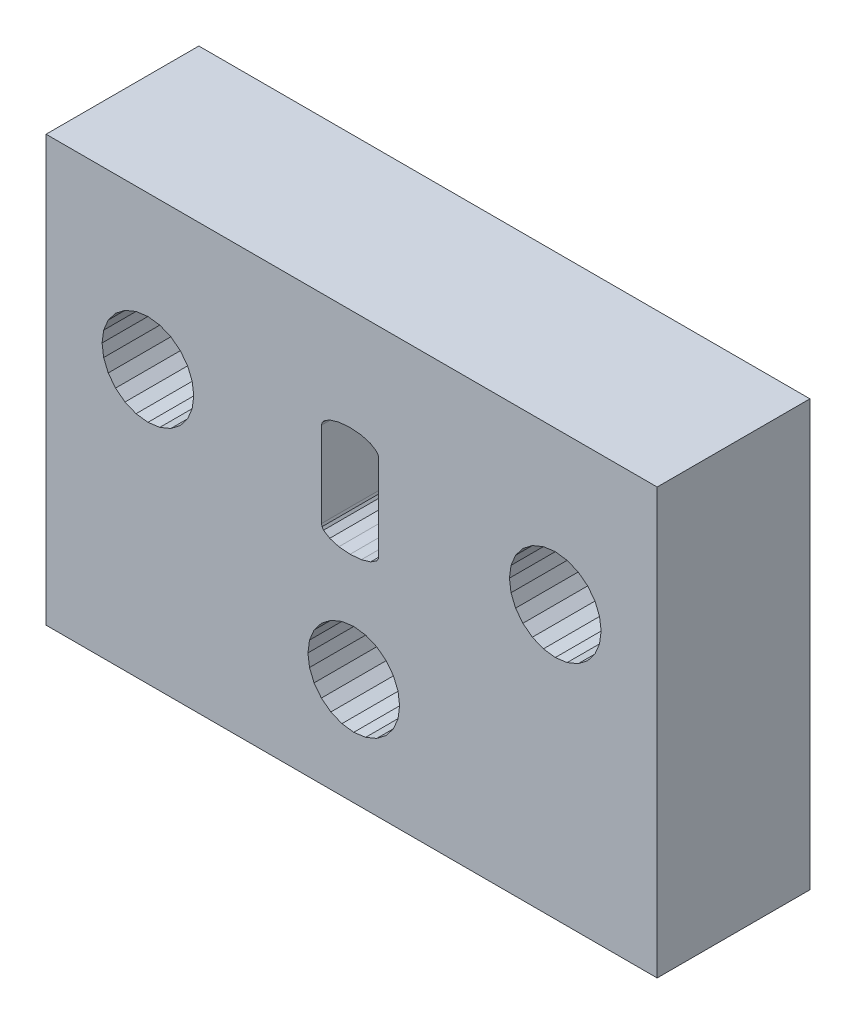
from build123d import *

# Parameters (mm, degrees)
SKETCH1_W           = 23.99999232
SKETCH1_H           = 16.699994656
BOSS_EXTRUDE1_DEPTH = 6


with BuildPart() as part:
    # Sketch1 → Boss-Extrude1 (new body)
    with BuildSketch(Plane.XY):
        with Locations((252.776898883, 87.516141094)):
            Rectangle(SKETCH1_W, SKETCH1_H)
        Polygon((254.420508276, 82.46614271), (254.600328979, 82.90026829), (254.661662472, 83.366142422), (254.600328979, 83.832016554), (254.420508276, 84.266142134), (254.134454846, 84.638934221), (253.76166276, 84.92498765), (253.32753718, 85.104808353), (252.861663048, 85.166141846), (252.395788915, 85.104808353), (251.961663336, 84.92498765), (251.588871249, 84.638934221), (251.30281782, 84.266142134), (251.122997117, 83.832016554), (251.061663624, 83.366142422), (251.122997117, 82.90026829), (251.30281782, 82.46614271), (251.588871249, 82.093350624), (251.961663336, 81.807297194), (252.395788915, 81.627476491), (252.861663048, 81.566142998), (253.32753718, 81.627476491), (253.76166276, 81.807297194), (254.134454846, 82.093350624), align=None, mode=Mode.SUBTRACT)
        Polygon((260.30990578, 88.127474411), (260.775779912, 88.066140918), (261.241654045, 88.127474411), (261.675779624, 88.307295114), (262.048571711, 88.593348544), (262.33462514, 88.96614063), (262.514445843, 89.40026621), (262.575779336, 89.866140342), (262.514445843, 90.332014474), (262.33462514, 90.766140054), (262.048571711, 91.138932141), (261.675779624, 91.42498557), (261.241654045, 91.604806273), (260.775779912, 91.666139766), (260.30990578, 91.604806273), (259.8757802, 91.42498557), (259.502988114, 91.138932141), (259.216934685, 90.766140054), (259.037113982, 90.332014474), (258.975780488, 89.866140342), (259.037113982, 89.40026621), (259.216934685, 88.96614063), (259.502988114, 88.593348544), (259.8757802, 88.307295114), align=None, mode=Mode.SUBTRACT)
        Polygon((246.335746671, 90.766140054), (246.049693242, 91.138932141), (245.676901155, 91.42498557), (245.242775575, 91.604806273), (244.776901443, 91.666139766), (244.311027311, 91.604806273), (243.876901731, 91.42498557), (243.504109644, 91.138932141), (243.218056215, 90.766140054), (243.038235512, 90.332014474), (242.976902019, 89.866140342), (243.038235512, 89.40026621), (243.218056215, 88.96614063), (243.504109644, 88.593348544), (243.876901731, 88.307295114), (244.311027311, 88.127474411), (244.776901443, 88.066140918), (245.242775575, 88.127474411), (245.676901155, 88.307295114), (246.049693242, 88.593348544), (246.335746671, 88.96614063), (246.515567374, 89.40026621), (246.576900867, 89.866140342), (246.515567374, 90.332014474), align=None, mode=Mode.SUBTRACT)
        Polygon((251.594211482, 88.030941424), (251.614308424, 87.934752995), (251.674599249, 87.845978104), (251.91576255, 87.690668939), (252.277126402, 87.585307372), (252.718115827, 87.55018685), (253.159105252, 87.585307372), (253.520469104, 87.690668939), (253.761632405, 87.845978104), (253.82192323, 87.934752995), (253.842020171, 88.030941424), (253.842020171, 91.377359106), (253.82192323, 91.473547535), (253.761632405, 91.562322426), (253.520469104, 91.717631591), (253.159105252, 91.822993158), (252.718115827, 91.85811368), (252.277126402, 91.822993158), (251.91576255, 91.717631591), (251.674599249, 91.562322426), (251.614308424, 91.473547535), (251.594211482, 91.377359106), align=None, mode=Mode.SUBTRACT)
    extrude(amount=BOSS_EXTRUDE1_DEPTH)


solid = part.part
